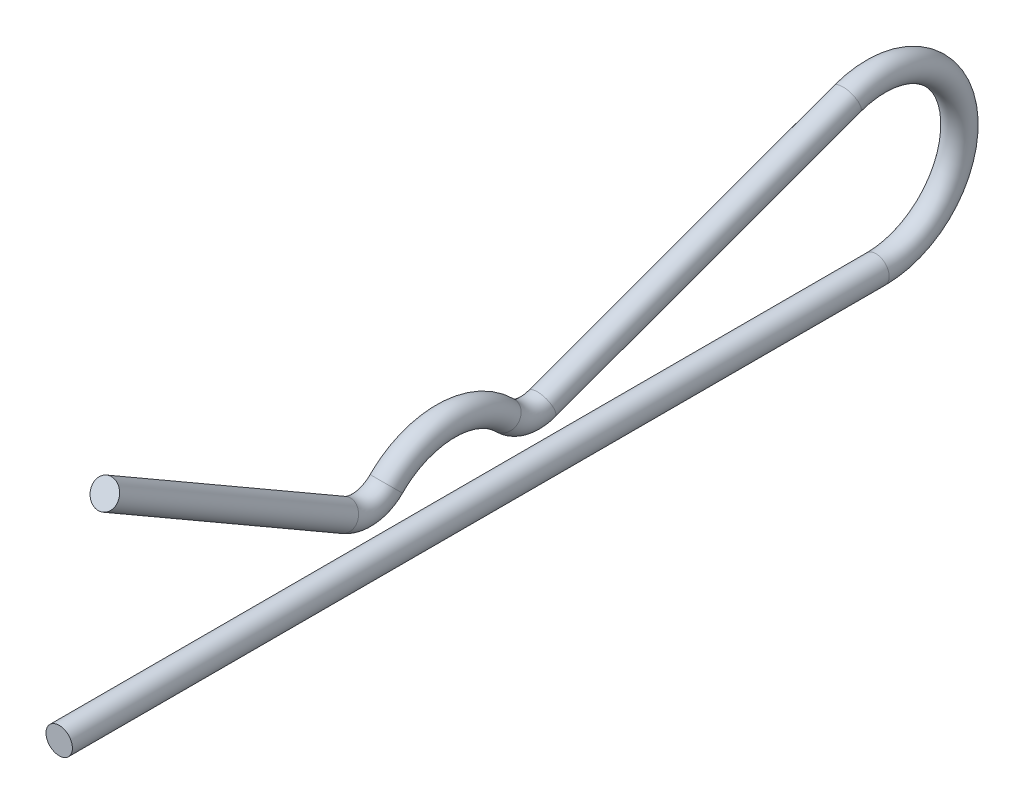
from build123d import *

# Parameters (mm, degrees)
SKETCH3_R = 0.5969


with BuildPart() as part:
    # Sweep1: sweep along a path in Sketch4
    with BuildLine(Plane(origin=(0, 0, 0), x_dir=(0, 0, -1), z_dir=(1, 0, 0))) as sweep1_path:
        Line((-18.57375, 4.859208931), (-7.776103247, -1.374815329))
        ThreePointArc((-7.776103247, -1.374815329), (-6.771462378, -1.573429786), (-5.854582736, -1.117268957))
        ThreePointArc((-5.854582736, -1.117268957), (-3.175, 0), (-0.495417264, -1.117268957))
        ThreePointArc((-0.495417264, -1.117268957), (0.28573535, -1.549197303), (1.176473152, -1.491338251))
        Line((1.176473152, -1.491338251), (14.975871107, 3.543419685))
        ThreePointArc((14.975871107, 3.543419685), (19.983040744, 0.656431604), (16.2687, -3.7719))
        Line((16.2687, -3.7719), (-20.6375, -3.7719))
    # Sketch3 → Sweep1 (sweep)
    with BuildSketch(Plane.XY.offset(20.6375)):
        with Locations((0, -3.7719)):
            Circle(SKETCH3_R)
    sweep(path=sweep1_path.line)


solid = part.part
